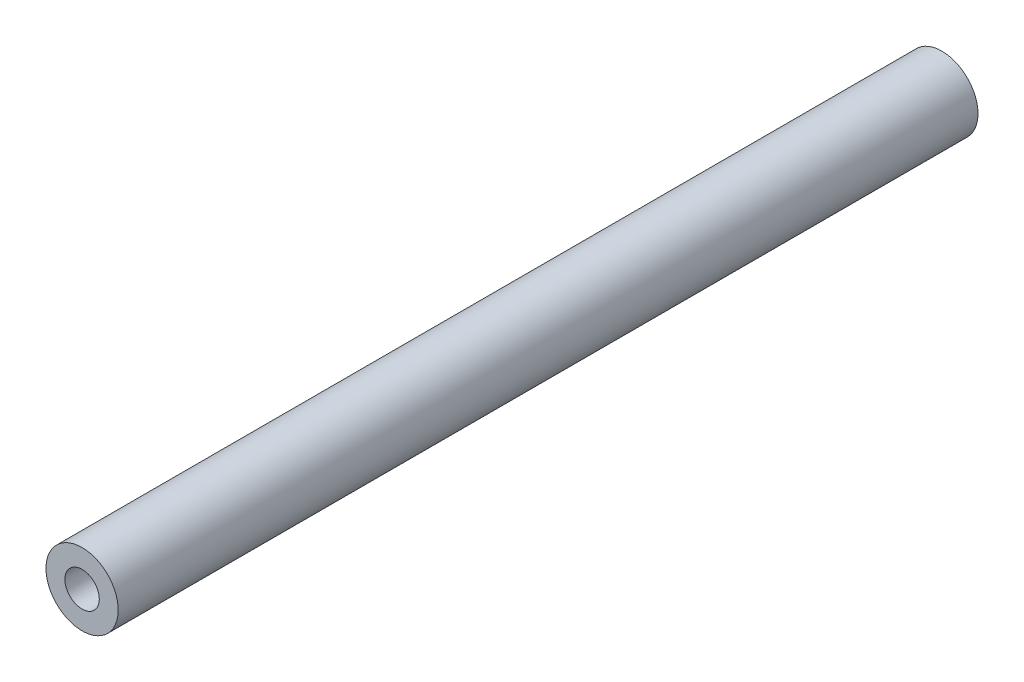
from build123d import *


with BuildPart() as part:
    # Sketch2 → Revolve1 (revolve)
    with BuildSketch(Plane(origin=(0, 0, 0), x_dir=(0, 0, -1), z_dir=(1, 0, 0))):
        Polygon((37.5, 1.5), (25.5, 1.5), (25.5, 0), (-25.5, 0), (-25.5, 1.5), (-37.5, 1.5), (-37.5, 3.15), (37.5, 3.15), align=None)
    revolve(axis=Axis((0, 0, 25.5), (0, 0, 1)))


solid = part.part
